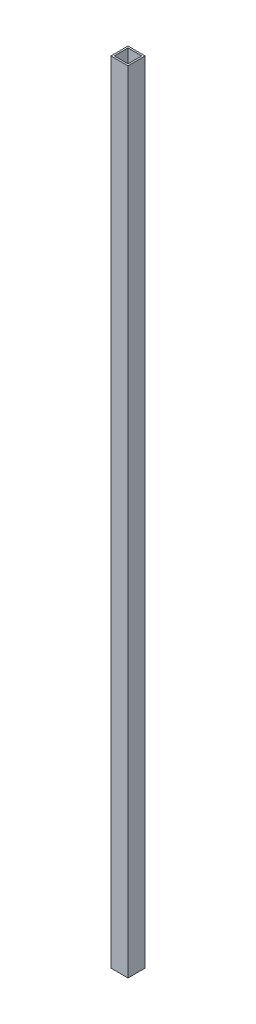
from build123d import *

# Parameters (mm, degrees)
SKETCH1_W                 = 25.4
SKETCH1_H                 = 25.4
SKETCH1_W_2               = 20.32
SKETCH1_H_2               = 20.32
EXTRUSION_1X1X0_1_1_DEPTH = 1168.4


with BuildPart() as part:
    # Sketch1 → Extrusion 1X1X0.1(1) (new body)
    with BuildSketch(Plane(origin=(0, 0, 0), x_dir=(-1, 0, 0), z_dir=(0, 1, 0))):
        with Locations((12.7, 12.7)):
            Rectangle(SKETCH1_W, SKETCH1_H)
        with Locations((12.7, 12.7)):
            Rectangle(SKETCH1_W_2, SKETCH1_H_2, mode=Mode.SUBTRACT)
    extrude(amount=EXTRUSION_1X1X0_1_1_DEPTH)


solid = part.part
